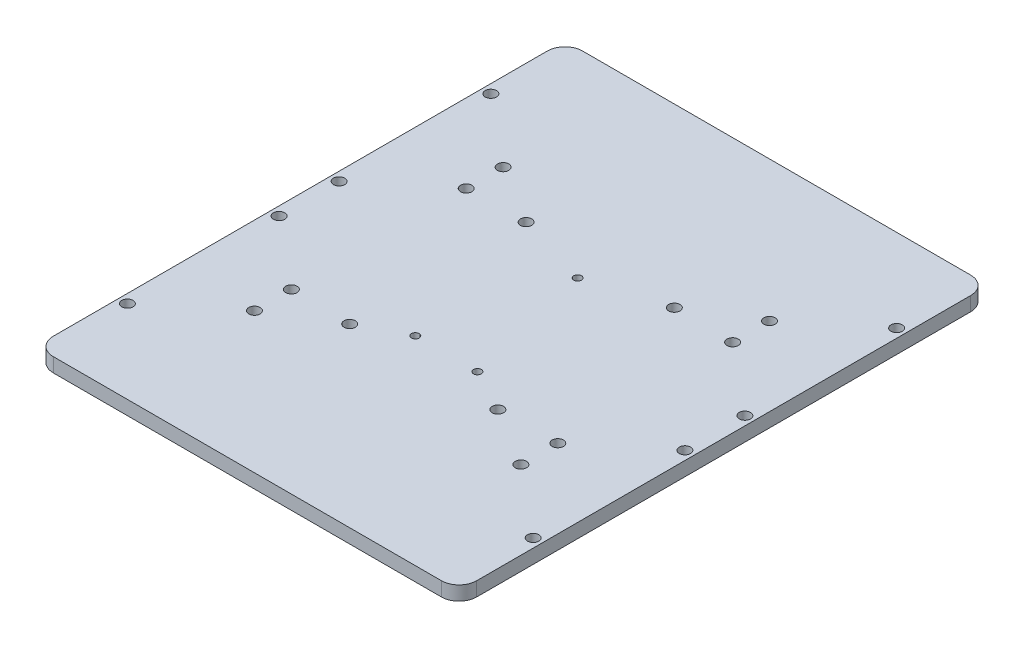
from build123d import *

# Parameters (mm, degrees)
SKETCH_1_W      = 120
SKETCH_1_H      = 150
SKETCH_1_R      = 1.6
SKETCH_1_R_2    = 1.1
EXTRUDE_1_DEPTH = 4
FILLET_1_R      = 5


with BuildPart() as part:
    # 草图1 → 凸台-拉伸1 (new body)
    with BuildSketch(Plane(origin=(0, 0, 0), x_dir=(1, 0, 0), z_dir=(0, 1, 0))):
        Rectangle(SKETCH_1_W, SKETCH_1_H)
        with Locations((-57.5, 51.5)):
            Circle(SKETCH_1_R, mode=Mode.SUBTRACT)
        with Locations((-57.5, 8.5)):
            Circle(SKETCH_1_R, mode=Mode.SUBTRACT)
        with Locations((-37.75, 35.23)):
            Circle(SKETCH_1_R, mode=Mode.SUBTRACT)
        with Locations((-37.75, 24.77)):
            Circle(SKETCH_1_R, mode=Mode.SUBTRACT)
        with Locations((-57.5, -8.5)):
            Circle(SKETCH_1_R, mode=Mode.SUBTRACT)
        with Locations((-37.75, -24.77)):
            Circle(SKETCH_1_R, mode=Mode.SUBTRACT)
        with Locations((-37.75, -35.23)):
            Circle(SKETCH_1_R, mode=Mode.SUBTRACT)
        with Locations((-57.5, -51.5)):
            Circle(SKETCH_1_R, mode=Mode.SUBTRACT)
        with Locations((57.5, -51.5)):
            Circle(SKETCH_1_R, mode=Mode.SUBTRACT)
        with Locations((37.75, -35.23)):
            Circle(SKETCH_1_R, mode=Mode.SUBTRACT)
        with Locations((37.75, -24.77)):
            Circle(SKETCH_1_R, mode=Mode.SUBTRACT)
        with Locations((57.5, -8.5)):
            Circle(SKETCH_1_R, mode=Mode.SUBTRACT)
        with Locations((57.5, 8.5)):
            Circle(SKETCH_1_R, mode=Mode.SUBTRACT)
        with Locations((37.75, 24.77)):
            Circle(SKETCH_1_R, mode=Mode.SUBTRACT)
        with Locations((37.75, 35.23)):
            Circle(SKETCH_1_R, mode=Mode.SUBTRACT)
        with Locations((57.5, 51.5)):
            Circle(SKETCH_1_R, mode=Mode.SUBTRACT)
        with Locations((0, 18.6)):
            Circle(SKETCH_1_R_2, mode=Mode.SUBTRACT)
        with Locations((8.8, -18.6)):
            Circle(SKETCH_1_R_2, mode=Mode.SUBTRACT)
        with Locations((-8.8, -18.6)):
            Circle(SKETCH_1_R_2, mode=Mode.SUBTRACT)
        with Locations((-21, 25)):
            Circle(SKETCH_1_R, mode=Mode.SUBTRACT)
        with Locations((21, 25)):
            Circle(SKETCH_1_R, mode=Mode.SUBTRACT)
        with Locations((21, -25)):
            Circle(SKETCH_1_R, mode=Mode.SUBTRACT)
        with Locations((-21, -25)):
            Circle(SKETCH_1_R, mode=Mode.SUBTRACT)
    extrude(amount=EXTRUDE_1_DEPTH)

    # 圆角1
    fillet_1_edges = [part.edges().sort_by_distance(p)[0] for p in [
        (60, 2, 75),
        (-60, 2, 75),
        (-60, 2, -75),
        (60, 2, -75),
    ]]
    fillet(fillet_1_edges, radius=FILLET_1_R)


solid = part.part
